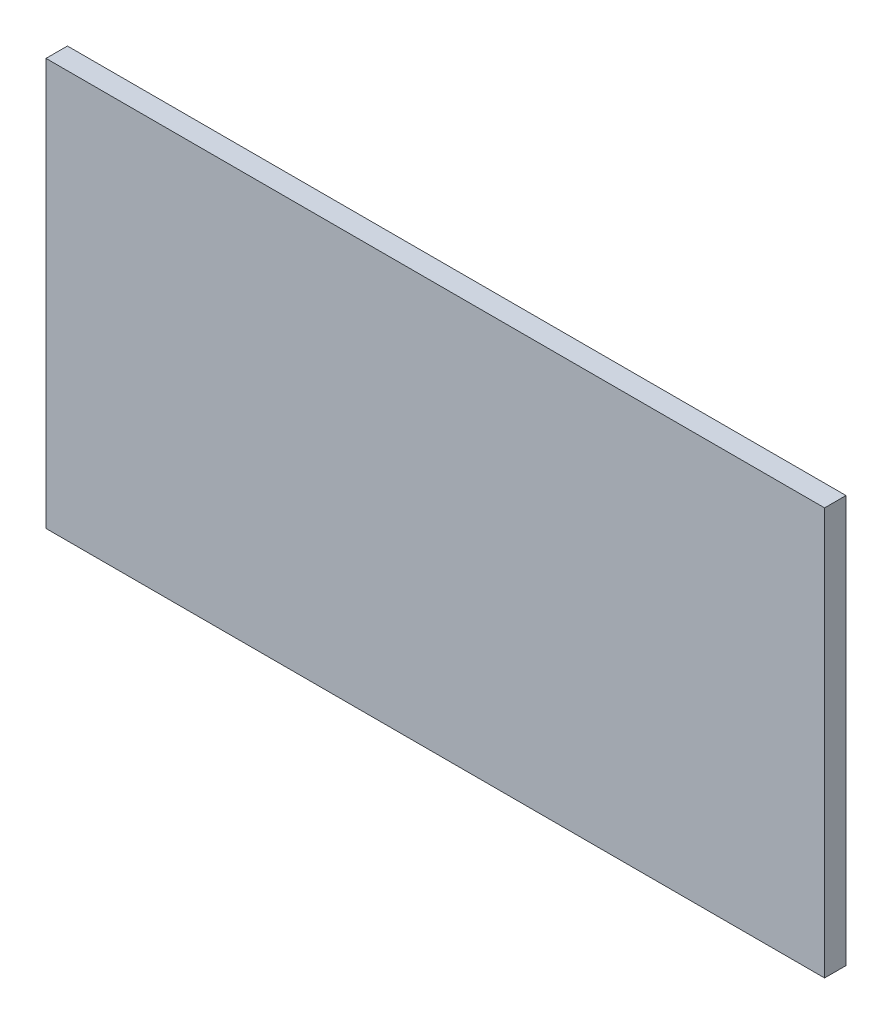
from build123d import *

# Parameters (mm, degrees)
SKETCH1_W      = 10900
SKETCH1_H      = 5700
EXTRUDE1_DEPTH = 300


with BuildPart() as part:
    # Sketch1 → Extrude1 (new body)
    with BuildSketch(Plane.XY):
        with Locations((-5450, 2850)):
            Rectangle(SKETCH1_W, SKETCH1_H)
    extrude(amount=EXTRUDE1_DEPTH)


solid = part.part
